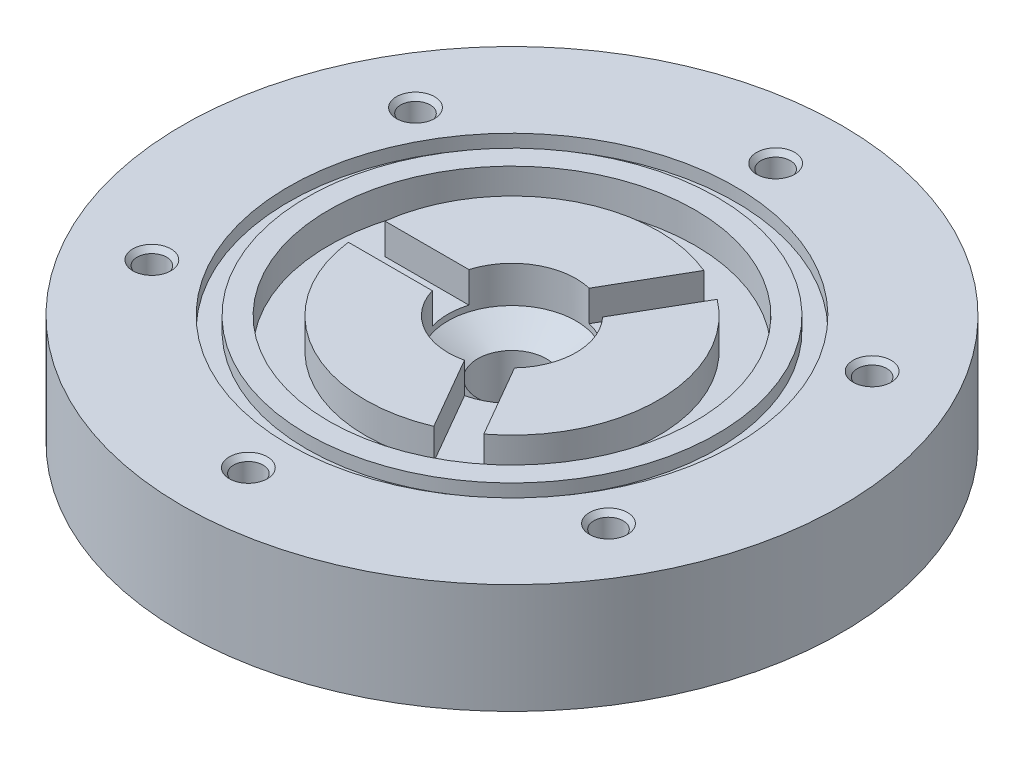
from build123d import *

# Parameters (mm, degrees)
SKETCH1_R                        = 57.15
BOSS_EXTRUDE1_DEPTH              = 19.05
F_7_8_0_875_DIAMETER_HOLE1_D     = 22.225
F_7_8_0_875_DIAMETER_HOLE1_DEPTH = 6.35
F_7_8_0_875_DIAMETER_HOLE1_TIP   = 6.677063629
CUT_EXTRUDE1_DEPTH               = 84.037024874
CUT_EXTRUDE1_DEPTH_BACK          = 84.037024874
SKETCH4_R                        = 5.953125
ANNULUS_START                    = -5.334
ANNULUS_CHANNEL_R                = 31.75
ANNULUS_CHANNEL_DEPTH_DEPTH      = 5.334
SKETCH7_R                        = 38.735
SKETCH7_R_2                      = 35.56
CUT_EXTRUDE5_DEPTH               = 2.286
CIRPATTERN1_COUNT                = 6


with BuildPart() as part:
    # Sketch1 → Boss-Extrude1 (new body)
    with BuildSketch(Plane(origin=(0, 0, 0), x_dir=(1, 0, 0), z_dir=(0, 1, 0))):
        Circle(SKETCH1_R)
    extrude(amount=BOSS_EXTRUDE1_DEPTH)

    # 7_8 _0.875_ Diameter Hole1
    with Locations(Plane(origin=(0, 19.05, 0), x_dir=(1, 0, 0), z_dir=(0, 1, 0))):
        with Locations((0, 0)):
            Hole(F_7_8_0_875_DIAMETER_HOLE1_D / 2, depth=F_7_8_0_875_DIAMETER_HOLE1_DEPTH)
            with Locations((0, 0, -(F_7_8_0_875_DIAMETER_HOLE1_DEPTH + F_7_8_0_875_DIAMETER_HOLE1_TIP / 2))):  # 118° drill point
                Cone(0, F_7_8_0_875_DIAMETER_HOLE1_D / 2, F_7_8_0_875_DIAMETER_HOLE1_TIP, mode=Mode.SUBTRACT)

    # Sketch4 → Cut-Extrude1 (cut, two sides: drawn at the far end of the back side and taken through both)
    with BuildSketch(Plane(origin=(0, 19.05, 0), x_dir=(1, 0, 0), z_dir=(0, 1, 0)).offset(-CUT_EXTRUDE1_DEPTH_BACK)):
        Circle(SKETCH4_R)
    extrude(amount=CUT_EXTRUDE1_DEPTH + CUT_EXTRUDE1_DEPTH_BACK, mode=Mode.SUBTRACT)

    # Annulus Channel → Annulus Channel Depth (cut)
    with BuildSketch(Plane(origin=(0, 19.05, 0), x_dir=(1, 0, 0), z_dir=(0, 1, 0)).offset(ANNULUS_START)):
        Circle(ANNULUS_CHANNEL_R)
        with BuildLine():
            Line((-10.649273743, 3.175), (-25.200781238, 3.175))
            ThreePointArc((-25.200781238, 3.175), (-12.7, 21.997045256), (9.850759962, 23.412016747))
            Line((9.850759962, 23.412016747), (2.575006214, 10.810041593))
            ThreePointArc((2.575006214, 10.810041593), (5.55625, 9.6237073), (8.074267528, 7.635041593))
            Line((8.074267528, 7.635041593), (15.350021276, 20.237016747))
            ThreePointArc((15.350021276, 20.237016747), (25.4, 0), (15.350021276, -20.237016747))
            Line((15.350021276, -20.237016747), (8.074267528, -7.635041593))
            ThreePointArc((8.074267528, -7.635041593), (5.55625, -9.6237073), (2.575006214, -10.810041593))
            Line((2.575006214, -10.810041593), (9.850759962, -23.412016747))
            ThreePointArc((9.850759962, -23.412016747), (-12.7, -21.997045256), (-25.200781238, -3.175))
            Line((-25.200781238, -3.175), (-10.649273743, -3.175))
            ThreePointArc((-10.649273743, -3.175), (-11.1125, 0), (-10.649273743, 3.175))
        make_face(mode=Mode.SUBTRACT)
    extrude(amount=ANNULUS_CHANNEL_DEPTH_DEPTH, mode=Mode.SUBTRACT)

    # Sketch7 → Cut-Extrude5 (cut)
    with BuildSketch(Plane(origin=(0, 19.05, 0), x_dir=(1, 0, 0), z_dir=(0, 1, 0))):
        Circle(SKETCH7_R)
        Circle(SKETCH7_R_2, mode=Mode.SUBTRACT)
    extrude(amount=-CUT_EXTRUDE5_DEPTH, mode=Mode.SUBTRACT)

    # Sketch9 → 1_4-20 Tapped Hole1 (revolve, cut)
    with BuildSketch(Plane(origin=(0, 19.05, -45.72), x_dir=(0, 0, 1), z_dir=(1, 0, 0))):
        Polygon((0, 0), (0, 15.503816902), (2.5527, 13.97), (2.5527, 0.861971048), (3.302, 0), align=None)
    f_1_4_20_tapped_hole1 = revolve(axis=Axis((0, 25.4, -45.72), (0, -1, 0)), mode=Mode.SUBTRACT)

    # CirPattern1: 1_4-20 Tapped Hole1 ×6 about axis
    cirpattern1_axis = Axis((0, 12.7, 0), (0, 1, 0))
    for i in range(1, CIRPATTERN1_COUNT):
        add(f_1_4_20_tapped_hole1.rotate(cirpattern1_axis, i * 360 / CIRPATTERN1_COUNT), mode=Mode.SUBTRACT)


solid = part.part
